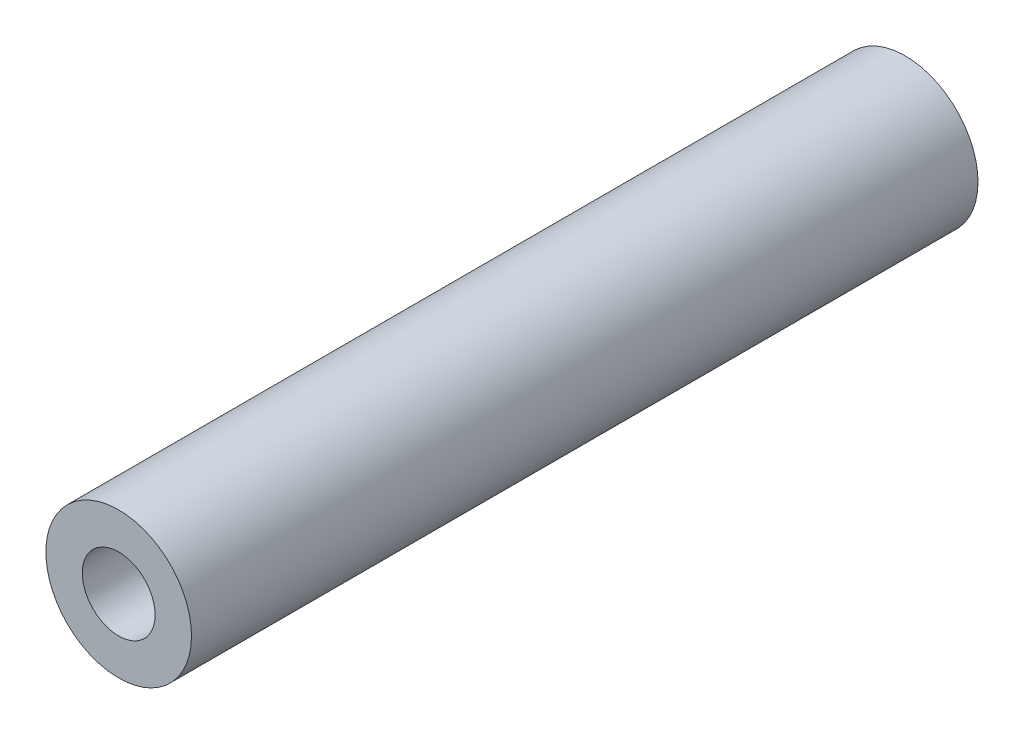
from build123d import *

# Parameters (mm, degrees)
CROQUIS1_R              = 1
CROQUIS1_R_2            = 0.5
SALIENTE_EXTRUIR1_DEPTH = 10.8


with BuildPart() as part:
    # Croquis1 → Saliente-Extruir1 (new body)
    with BuildSketch(Plane.XY):
        Circle(CROQUIS1_R)
        Circle(CROQUIS1_R_2, mode=Mode.SUBTRACT)
    extrude(amount=SALIENTE_EXTRUIR1_DEPTH)


solid = part.part
